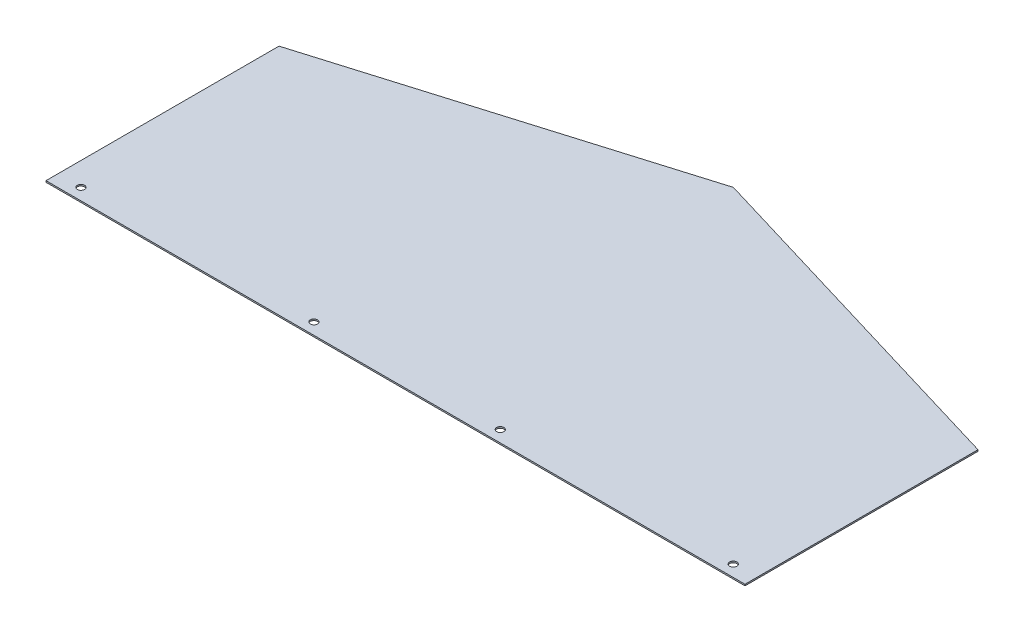
from build123d import *

# Parameters (mm, degrees)
BOSS_EXTRUDE1_DEPTH              = 3.175
F_5_8_0_625_DIAMETER_HOLE1_D     = 15.875
F_5_8_0_625_DIAMETER_HOLE1_DEPTH = 3.175


with BuildPart() as part:
    # Sketch1 → Boss-Extrude1 (new body)
    with BuildSketch(Plane(origin=(0, 0, 0), x_dir=(1, 0, 0), z_dir=(0, 1, 0))):
        Polygon((0, 0), (1524, 0), (1524, 508), (762, 736.6), (0, 508), align=None)
    extrude(amount=BOSS_EXTRUDE1_DEPTH)

    # 5/8 (0.625) Diameter Hole1
    with Locations(Plane.XZ):
        with Locations((50.8, -25.4), (558.8, -25.325960299), (965.2, -25.266728538), (1473.2, -25.192688837)):
            Hole(F_5_8_0_625_DIAMETER_HOLE1_D / 2, depth=F_5_8_0_625_DIAMETER_HOLE1_DEPTH)


solid = part.part
